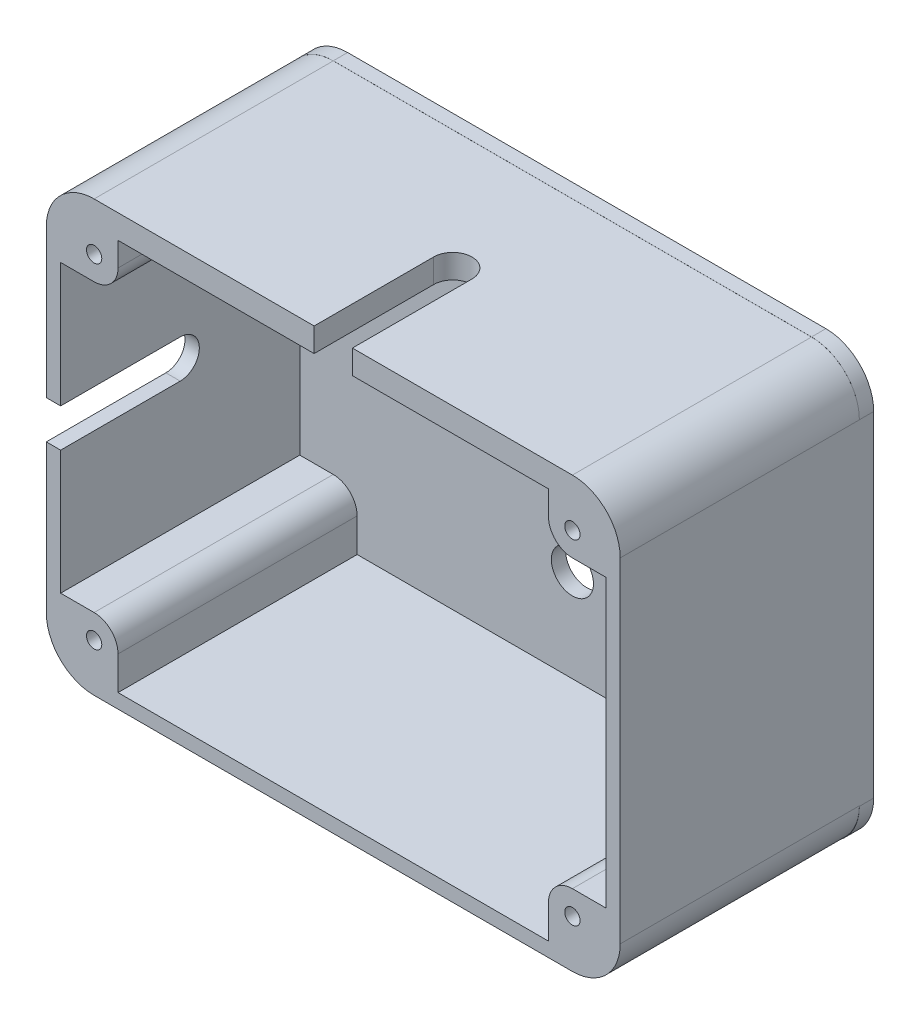
from build123d import *

# Parameters (mm, degrees)
SKETCH1_R           = 4.4
BOSS_EXTRUDE1_DEPTH = 3
SKETCH2_R           = 1.6
BOSS_EXTRUDE2_DEPTH = 50
CUT_EXTRUDE1_DEPTH  = 10
CUT_EXTRUDE2_DEPTH  = 10


with BuildPart() as part:
    # Sketch1 → Boss-Extrude1 (new body)
    with BuildSketch(Plane.XY):
        with BuildLine():
            Line((-50, 45), (50, 45))
            ThreePointArc((50, 45), (57.071067812, 42.071067812), (60, 35))
            Line((60, 35), (60, -35))
            ThreePointArc((60, -35), (57.071067812, -42.071067812), (50, -45))
            Line((50, -45), (-50, -45))
            ThreePointArc((-50, -45), (-57.071067812, -42.071067812), (-60, -35))
            Line((-60, -35), (-60, 35))
            ThreePointArc((-60, 35), (-57.071067812, 42.071067812), (-50, 45))
        make_face()
        with Locations((0, 22.5)):
            Circle(SKETCH1_R, mode=Mode.SUBTRACT)
        with Locations((0, -22.5)):
            Circle(SKETCH1_R, mode=Mode.SUBTRACT)
    extrude(amount=BOSS_EXTRUDE1_DEPTH)

    # Sketch2 → Boss-Extrude2 (add)
    with BuildSketch(Plane(origin=(0, -44.902942235, 3), x_dir=(1, 0, 0), z_dir=(0, 0, 1))):
        with BuildLine():
            Line((-50, 0), (50, 0))
            ThreePointArc((50, 0), (57.071067812, 2.928932188), (60, 10))
            Line((60, 10), (60, 79.887698494))
            ThreePointArc((60, 79.887698494), (57.071067812, 86.958766306), (50, 89.887698494))
            Line((50, 89.887698494), (-50, 89.887698494))
            ThreePointArc((-50, 89.887698494), (-57.071067812, 86.958766306), (-60, 79.887698494))
            Line((-60, 79.887698494), (-60, 10))
            ThreePointArc((-60, 10), (-57.071067812, 2.928932188), (-50, 0))
        make_face()
        with Locations((-50, 79.887698494)):
            Circle(SKETCH2_R, mode=Mode.SUBTRACT)
        with Locations((-50, 10)):
            Circle(SKETCH2_R, mode=Mode.SUBTRACT)
        with Locations((50, 10)):
            Circle(SKETCH2_R, mode=Mode.SUBTRACT)
        with Locations((50, 79.887698494)):
            Circle(SKETCH2_R, mode=Mode.SUBTRACT)
        with BuildLine():
            Line((-45, 10), (-45, 3))
            Line((-45, 3), (45, 3))
            Line((45, 3), (45, 10))
            ThreePointArc((45, 10), (46.464466094, 13.535533906), (50, 15))
            Line((50, 15), (57, 15))
            Line((57, 15), (57, 74.887698494))
            Line((57, 74.887698494), (50, 74.887698494))
            ThreePointArc((50, 74.887698494), (46.464466094, 76.352164588), (45, 79.887698494))
            Line((45, 79.887698494), (45, 84.887698494))
            Line((45, 84.887698494), (-45, 84.887698494))
            Line((-45, 84.887698494), (-45, 79.887698494))
            ThreePointArc((-45, 79.887698494), (-46.464466094, 76.352164588), (-50, 74.887698494))
            Line((-50, 74.887698494), (-57, 74.887698494))
            Line((-57, 74.887698494), (-57, 15))
            Line((-57, 15), (-50, 15))
            ThreePointArc((-50, 15), (-46.464466094, 13.535533906), (-45, 10))
        make_face(mode=Mode.SUBTRACT)
    extrude(amount=BOSS_EXTRUDE2_DEPTH)

    # Sketch6 → Cut-Extrude1 (cut)
    with BuildSketch(Plane(origin=(0, 44.984756259, 0), x_dir=(1, 0, 0), z_dir=(0, 1, 0))):
        with BuildLine():
            Line((-4, -28), (-4, -53))
            Line((-4, -53), (4, -53))
            Line((4, -53), (4, -28))
            ThreePointArc((4, -28), (0, -24), (-4, -28))
        make_face()
    extrude(amount=-CUT_EXTRUDE1_DEPTH, mode=Mode.SUBTRACT)

    # Sketch7 → Cut-Extrude2 (cut)
    with BuildSketch(Plane.ZY.offset(60)):
        with BuildLine():
            Line((28, 4), (53, 4))
            Line((53, 4), (53, -4))
            Line((53, -4), (28, -4))
            ThreePointArc((28, -4), (24, 0), (28, 4))
        make_face()
    extrude(amount=-CUT_EXTRUDE2_DEPTH, mode=Mode.SUBTRACT)


solid = part.part
